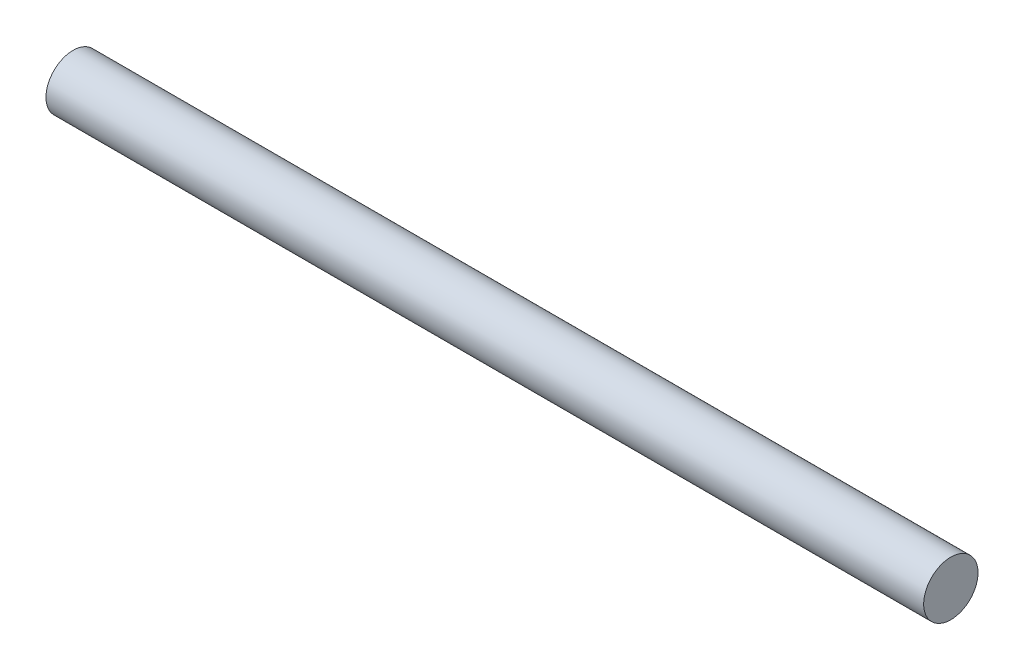
from build123d import *

# Parameters (mm, degrees)
SKETCH1_R           = 16.51
BOSS_EXTRUDE1_DEPTH = 533.4


with BuildPart() as part:
    # Sketch1 → Boss-Extrude1 (new body)
    with BuildSketch(Plane(origin=(0, 0, 0), x_dir=(0, 0, -1), z_dir=(1, 0, 0))):
        Circle(SKETCH1_R)
    extrude(amount=BOSS_EXTRUDE1_DEPTH)


solid = part.part
